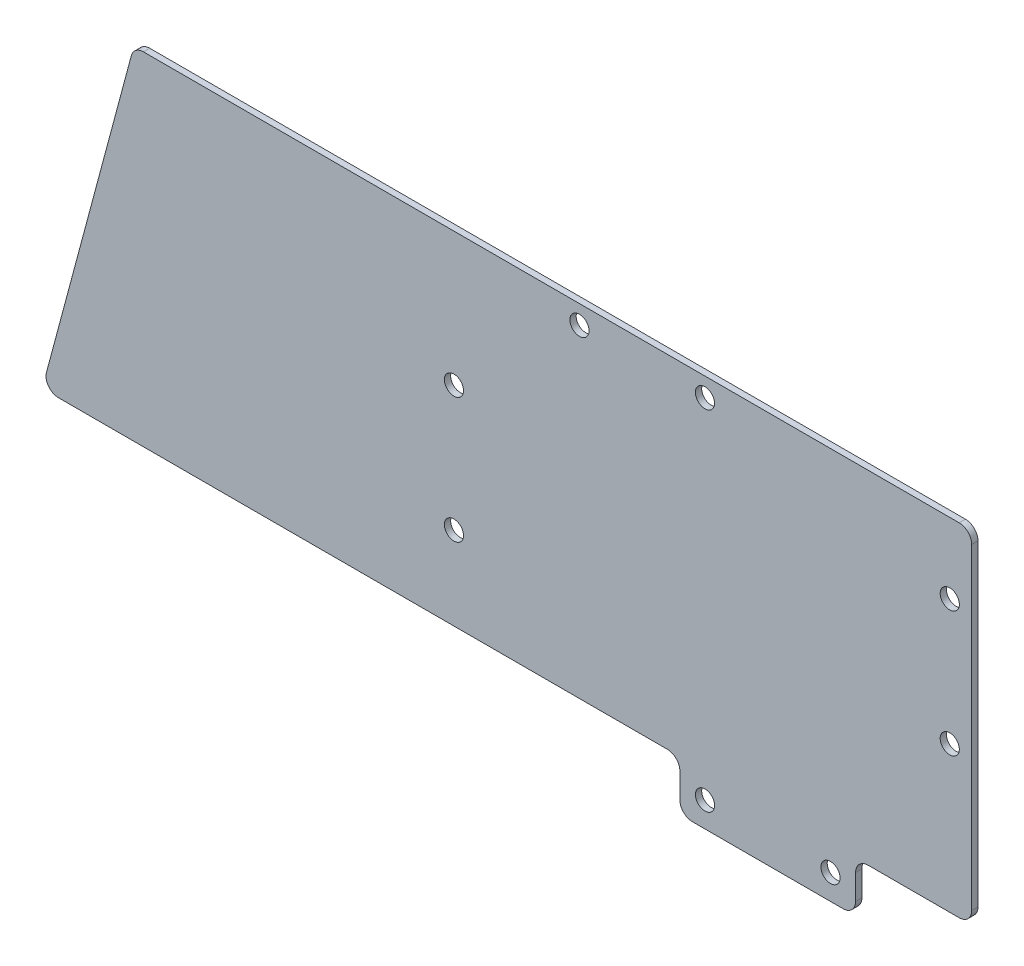
from build123d import *

# Parameters (mm, degrees)
SKETCH_1_W          = 28
SKETCH_1_H          = 8
SKETCH_1_R          = 1.525
EXTRUDE_1_DEPTH     = 1
SKETCH_2_R          = 1.525
CUT_EXTRUDE_1_DEPTH = 1
FILLET_1_R          = 2
SKETCH_3_R          = 1.525
CUT_EXTRUDE_2_DEPTH = 10
SKETCH_4_R          = 1.525
CUT_EXTRUDE_3_DEPTH = 10
EXTRUDE_2_DEPTH     = 1
FILLET_2_R          = 2


with BuildPart() as part:
    # 草图1 → 凸台-拉伸1 (new body)
    with BuildSketch(Plane.XY):
        Polygon((-4, 4), (24, 4), (42.5, 4), (42.5, 58.5), (-45, 58.5), (-45, 4), align=None)
        with Locations((10, 0)):
            Rectangle(SKETCH_1_W, SKETCH_1_H)
        with Locations((20, 0)):
            Circle(SKETCH_1_R, mode=Mode.SUBTRACT)
        Circle(SKETCH_1_R, mode=Mode.SUBTRACT)
    extrude(amount=EXTRUDE_1_DEPTH)

    # 草图2 → 切除-拉伸1 (cut)
    with BuildSketch(Plane.XY.offset(1)):
        with Locations((-40, 37.25)):
            Circle(SKETCH_2_R)
        with Locations((-40, 17.25)):
            Circle(SKETCH_2_R)
    extrude(amount=-CUT_EXTRUDE_1_DEPTH, mode=Mode.SUBTRACT)

    # 圆角1
    fillet_1_edges = [part.edges().sort_by_distance(p)[0] for p in [
        (42.5, 4, 0.5),
        (24, 4, 0.5),
        (24, -4, 0.5),
        (-4, -4, 0.5),
        (-4, 4, 0.5),
        (-45, 4, 0.5),
        (-45, 58.5, 0.5),
        (42.5, 58.5, 0.5),
    ]]
    fillet(fillet_1_edges, radius=FILLET_1_R)

    # 草图3 → 切除-拉伸2 (cut)
    with BuildSketch(Plane.XY.offset(1)):
        with Locations((39, 47.25)):
            Circle(SKETCH_3_R)
        with Locations((39, 27.25)):
            Circle(SKETCH_3_R)
    extrude(amount=-CUT_EXTRUDE_2_DEPTH, mode=Mode.SUBTRACT)

    # 草图4 → 切除-拉伸3 (cut)
    with BuildSketch(Plane.XY.offset(1)):
        with Locations((-20, 55.5)):
            Circle(SKETCH_4_R)
        with Locations((0, 55.5)):
            Circle(SKETCH_4_R)
    extrude(amount=-CUT_EXTRUDE_3_DEPTH, mode=Mode.SUBTRACT)

    # 草图5 → 凸台-拉伸2 (add)
    with BuildSketch(Plane.XY.offset(1)):
        with BuildLine():
            ThreePointArc((-45, 56.5), (-44.414213562, 57.914213562), (-43, 58.5))
            Line((-43, 58.5), (-91, 58.5))
            Line((-91, 58.5), (-105.603230987, 4))
            Line((-105.603230987, 4), (-43, 4))
            ThreePointArc((-43, 4), (-44.414213562, 4.585786438), (-45, 6))
            Line((-45, 6), (-45, 56.5))
        make_face()
    extrude(amount=-EXTRUDE_2_DEPTH)

    # 圆角2
    fillet_2_edges = [part.edges().sort_by_distance(p)[0] for p in [
        (-91, 58.5, 0.5),
        (-105.603230987, 4, 0.5),
    ]]
    fillet(fillet_2_edges, radius=FILLET_2_R)


solid = part.part
